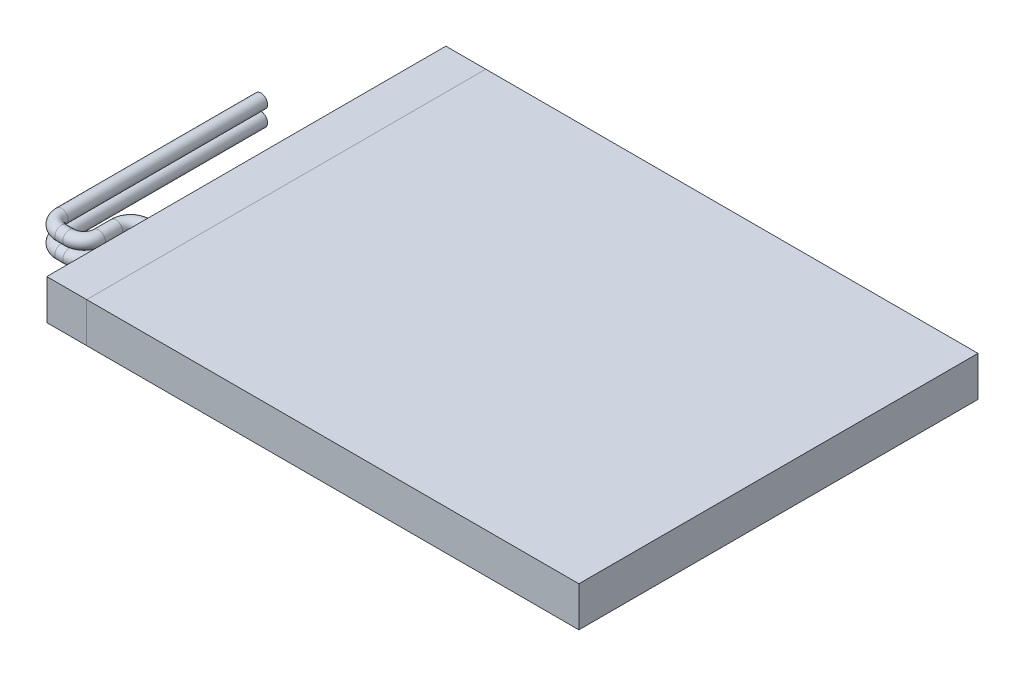
from build123d import *

# Parameters (mm, degrees)
SKETCH1_W              = 40
SKETCH1_H              = 30
BOSS_EXTRUDE1_DEPTH    = 3
SKETCH7_R              = 0.5
SKETCH5_R              = 0.5
SPLIT1_SURFACE_1_BACK  = 54.752
SPLIT1_SURFACE_1_DEPTH = 109.504
SPLIT1_SURFACE_2_BACK  = 54.752
SPLIT1_SURFACE_2_DEPTH = 109.504


with BuildPart() as part:
    # Sketch1 → Boss-Extrude1 (new body)
    with BuildSketch(Plane(origin=(0, 0, 0), x_dir=(1, 0, 0), z_dir=(0, 1, 0))):
        Rectangle(SKETCH1_W, SKETCH1_H)
    extrude(amount=BOSS_EXTRUDE1_DEPTH)

    # Sweep1: sweep along a path in Sketch3
    with BuildLine(Plane(origin=(0, 1.2, 0), x_dir=(-1, 0, 0), z_dir=(0, -1, 0))) as sweep1_path:
        Line((20, -7.5), (20.1, -7.5))
        ThreePointArc((20.1, -7.5), (20.877817459, -7.822182541), (21.2, -8.6))
        Line((21.2, -8.6), (21.2, -9.9))
        ThreePointArc((21.2, -9.9), (21.522182541, -10.677817459), (22.3, -11))
        Line((22.3, -11), (22.9, -11))
        ThreePointArc((22.9, -11), (23.677817459, -10.677817459), (24, -9.9))
        Line((24, -9.9), (24, 5.1))
    # Sketch7 → Sweep1 (sweep)
    with BuildSketch(Plane.ZY.offset(20)):
        with Locations((7.5, 1.2)):
            Circle(SKETCH7_R)
    sweep(path=sweep1_path.line)

    # Sweep2: sweep along a path in Sketch4
    with BuildLine(Plane(origin=(0, 2.4, 0), x_dir=(-1, 0, 0), z_dir=(0, -1, 0))) as sweep2_path:
        Line((20, -7.5), (20.1, -7.5))
        ThreePointArc((20.1, -7.5), (20.877817459, -7.822182541), (21.2, -8.6))
        Line((21.2, -8.6), (21.2, -9.9))
        ThreePointArc((21.2, -9.9), (21.522182541, -10.677817459), (22.3, -11))
        Line((22.3, -11), (22.9, -11))
        ThreePointArc((22.9, -11), (23.677817459, -10.677817459), (24, -9.9))
        Line((24, -9.9), (24, 5.1))
    # Sketch5 → Sweep2 (sweep)
    with BuildSketch(Plane.ZY.offset(20)):
        with Locations((7.5, 2.4)):
            Circle(SKETCH5_R)
    sweep(path=sweep2_path.line)


with BuildPart() as body_2:
    # Split1: the piece behind the surface
    add(part.part)
    # Split1 surface: a surface, the sketch's curves swept straight by 109.504 mm
    with BuildLine(Plane(origin=(0, 3, 0), x_dir=(1, 0, 0), z_dir=(0, 1, 0)).offset(-SPLIT1_SURFACE_1_BACK), mode=Mode.PRIVATE) as split1_surface_1_path:
        Line((-20, 15), (-17, 15))
        Line((-17, 15), (-17, -15))
        Line((-17, -15), (-20, -15))
        Line((-20, -15), (-20, 15))
    split1_surface_1 = Shell.extrude(split1_surface_1_path.wire(), (0 * SPLIT1_SURFACE_1_DEPTH, 1 * SPLIT1_SURFACE_1_DEPTH, 0 * SPLIT1_SURFACE_1_DEPTH))
    split(bisect_by=split1_surface_1, keep=Keep.BOTTOM)


with BuildPart() as part_1:
    add(part.part)

    # Split1: split by a surface, the side it looks to stays
    # Split1 surface: a surface, the sketch's curves swept straight by 109.504 mm
    with BuildLine(Plane(origin=(0, 3, 0), x_dir=(1, 0, 0), z_dir=(0, 1, 0)).offset(-SPLIT1_SURFACE_2_BACK), mode=Mode.PRIVATE) as split1_surface_2_path:
        Line((-20, 15), (-17, 15))
        Line((-17, 15), (-17, -15))
        Line((-17, -15), (-20, -15))
        Line((-20, -15), (-20, 15))
    split1_surface_2 = Shell.extrude(split1_surface_2_path.wire(), (0 * SPLIT1_SURFACE_2_DEPTH, 1 * SPLIT1_SURFACE_2_DEPTH, 0 * SPLIT1_SURFACE_2_DEPTH))
    split(bisect_by=split1_surface_2, keep=Keep.TOP)


solid = Compound([body_2.part, part_1.part])
